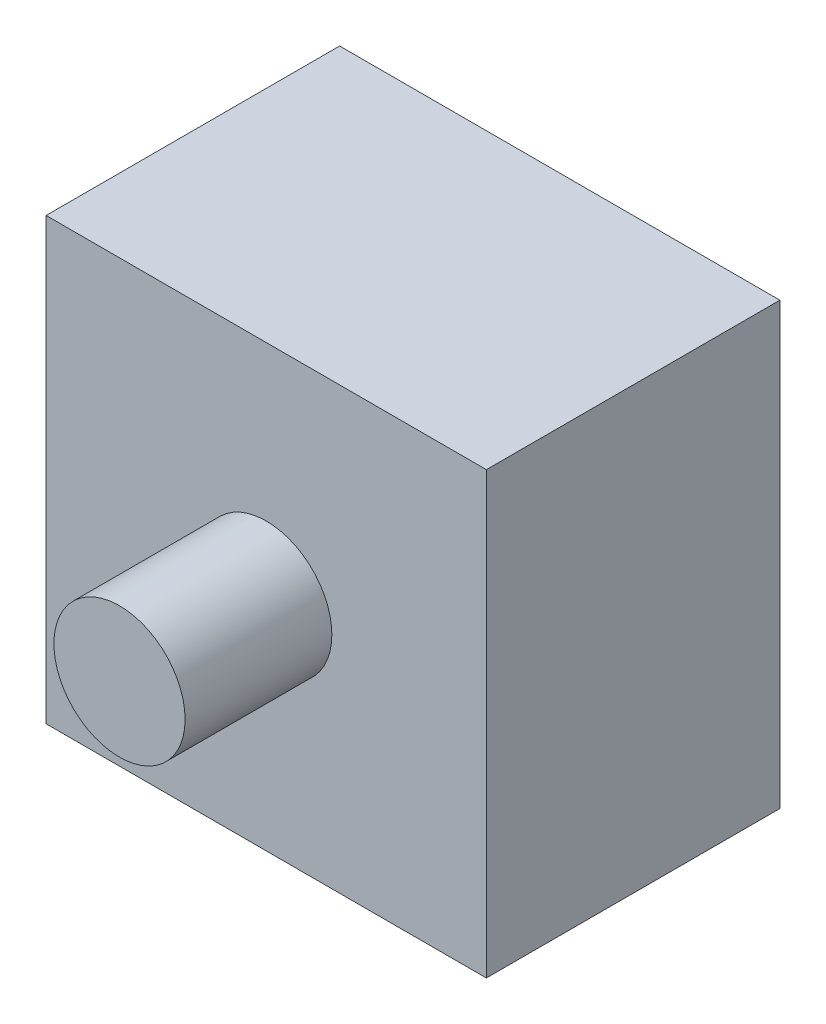
from build123d import *

# Parameters (mm, degrees)
SKETCH1_W           = 3
SKETCH1_H           = 3
BOSS_EXTRUDE1_DEPTH = 2
SKETCH2_R           = 0.44702456
BOSS_EXTRUDE2_DEPTH = 1


with BuildPart() as part:
    # Sketch1 → Boss-Extrude1 (new body)
    with BuildSketch(Plane.XY):
        Rectangle(SKETCH1_W, SKETCH1_H)
    extrude(amount=BOSS_EXTRUDE1_DEPTH)

    # Sketch2 → Boss-Extrude2 (add)
    with BuildSketch(Plane.XY.offset(2)):
        Circle(SKETCH2_R)
    extrude(amount=BOSS_EXTRUDE2_DEPTH)


solid = part.part
